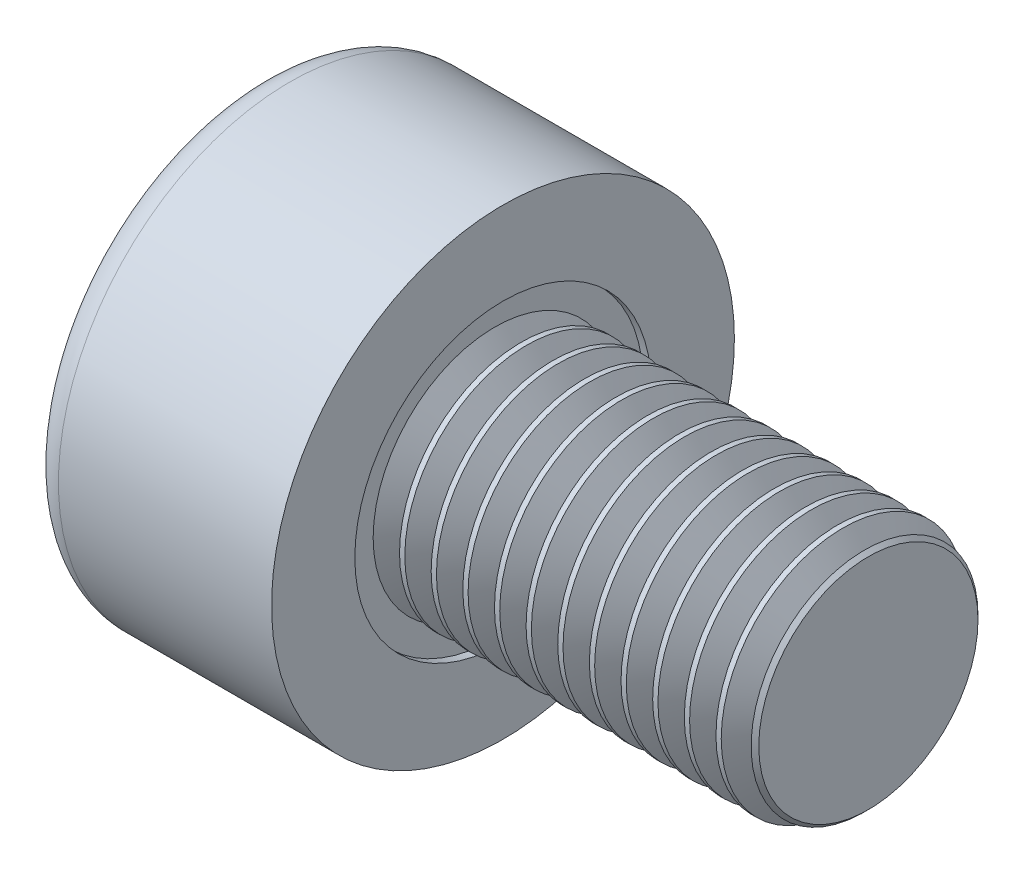
from build123d import *

# Parameters (mm, degrees)
SKETCH1_R           = 1.9
BASEHEAD_DEPTH      = 2
SKETCH2_R           = 1
BASEBODY_DEPTH      = 3
HEXAGONSOCKET_DEPTH = 1
TOPFILLET_R         = 0.25
CHAMFER1_SIZE       = 0.1
LPATTERN10_COUNT    = 12
LPATTERN10_PITCH    = 0.2598


with BuildPart() as part:
    # Sketch1 → BaseHead (new body)
    with BuildSketch(Plane(origin=(0, 0, 0), x_dir=(0, 0, -1), z_dir=(1, 0, 0))):
        Circle(SKETCH1_R)
    extrude(amount=BASEHEAD_DEPTH)

    # Sketch2 → BaseBody (add)
    with BuildSketch(Plane(origin=(2, 0, 0), x_dir=(0, 0, -1), z_dir=(1, 0, 0))):
        Circle(SKETCH2_R)
    extrude(amount=BASEBODY_DEPTH)

    # Sketch3 → HexagonSocket (cut)
    with BuildSketch(Plane(origin=(0, 0, 0), x_dir=(0, 0, -1), z_dir=(1, 0, 0))):
        Polygon((0.866025404, 0), (0.433012702, 0.75), (-0.433012702, 0.75), (-0.866025404, 0), (-0.433012702, -0.75), (0.433012702, -0.75), align=None)
    extrude(amount=HEXAGONSOCKET_DEPTH, mode=Mode.SUBTRACT)

    # Sketch4 → Cut-Revolve1 (revolve, cut)
    with BuildSketch(Plane(origin=(-4.19613823, 0.75, 0), x_dir=(-1, 0, 0), z_dir=(0, 0, 1))):
        Polygon((-5.19613823, 1.5), (-5.629150931, 0.75), (-5.19613823, 0.75), align=None)
    revolve(axis=Axis((0.838992387, 0, 0), (-1, 0, 0)), mode=Mode.SUBTRACT)

    # TopFillet
    topfillet_edges = [part.edges().sort_by_distance(p)[0] for p in [
        (0, 0, 1.9),
    ]]
    fillet(topfillet_edges, radius=TOPFILLET_R)

    # Chamfer1
    chamfer1_edges = [part.edges().sort_by_distance(p)[0] for p in [
        (5, 0, 1),
    ]]
    chamfer(chamfer1_edges, length=CHAMFER1_SIZE)

    # Sketch5 → Cut-Revolve10 (revolve, cut)
    with BuildSketch(Plane.XY):
        Polygon((4.9, 0.8125055), (5.00825, 1), (5.00825, 1.2165), (4.79175, 1.2165), (4.79175, 1), align=None)
    cut_revolve10 = revolve(axis=Axis((0, 0, 0), (1, 0, 0)), mode=Mode.SUBTRACT)

    # LPattern10: Cut-Revolve10 ×12
    with Locations(*[(-i * LPATTERN10_PITCH, 0, 0) for i in range(1, LPATTERN10_COUNT)]):
        add(cut_revolve10, mode=Mode.SUBTRACT)


solid = part.part
